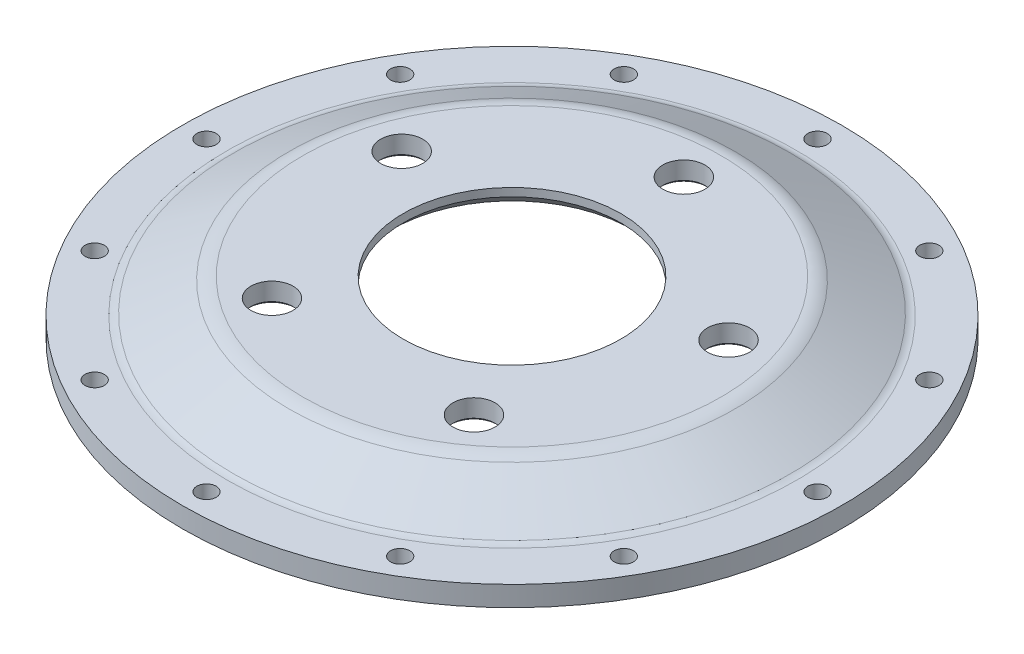
from build123d import *

# Parameters (mm, degrees)
SKETCH1_R           = 109.6
SKETCH1_R_2         = 3.2125
SKETCH1_R_3         = 93.6
BOSS_EXTRUDE1_DEPTH = 6.7
SKETCH2_R           = 72
SKETCH2_R_2         = 36.2
SKETCH2_R_3         = 7
BOSS_EXTRUDE3_DEPTH = 6.7
FILLET1_R           = 10
FILLET2_R           = 5
CHAMFER1_SIZE       = 4
CHAMFER2_SIZE       = 0.8
FILLET7_R           = 2.5
FILLET8_R           = 2.5


with BuildPart() as part:
    # Sketch1 → Boss-Extrude1 (new body)
    with BuildSketch(Plane(origin=(0, 0, 0), x_dir=(1, 0, 0), z_dir=(0, 1, 0))):
        with Locations(Location((0, 0, 0), (0, 0, 270))):
            Circle(SKETCH1_R)
        with Locations(Location((0, 101.6, 0), (0, 0, 270))):
            Circle(SKETCH1_R_2, mode=Mode.SUBTRACT)
        with Locations(Location((0, 0, 0), (0, 0, 270))):
            Circle(SKETCH1_R_3, mode=Mode.SUBTRACT)
        with Locations(Location((50.8, 87.988181025, 0), (0, 0, 270))):
            Circle(SKETCH1_R_2, mode=Mode.SUBTRACT)
        with Locations(Location((87.988181025, 50.8, 0), (0, 0, 270))):
            Circle(SKETCH1_R_2, mode=Mode.SUBTRACT)
        with Locations(Location((101.6, 0, 0), (0, 0, 270))):
            Circle(SKETCH1_R_2, mode=Mode.SUBTRACT)
        with Locations(Location((87.988181025, -50.8, 0), (0, 0, 270))):
            Circle(SKETCH1_R_2, mode=Mode.SUBTRACT)
        with Locations(Location((50.8, -87.988181024, 0), (0, 0, 270))):
            Circle(SKETCH1_R_2, mode=Mode.SUBTRACT)
        with Locations(Location((0, -101.6, 0), (0, 0, 270))):
            Circle(SKETCH1_R_2, mode=Mode.SUBTRACT)
        with Locations(Location((-50.8, -87.988181025, 0), (0, 0, 270))):
            Circle(SKETCH1_R_2, mode=Mode.SUBTRACT)
        with Locations(Location((-87.988181024, -50.8, 0), (0, 0, 270))):
            Circle(SKETCH1_R_2, mode=Mode.SUBTRACT)
        with Locations(Location((-101.6, 0, 0), (0, 0, 270))):
            Circle(SKETCH1_R_2, mode=Mode.SUBTRACT)
        with Locations(Location((-87.988181024, 50.8, 0), (0, 0, 270))):
            Circle(SKETCH1_R_2, mode=Mode.SUBTRACT)
        with Locations(Location((-50.8, 87.988181024, 0), (0, 0, 270))):
            Circle(SKETCH1_R_2, mode=Mode.SUBTRACT)
    extrude(amount=BOSS_EXTRUDE1_DEPTH)



with BuildPart() as body_2:
    # Sketch2 → Boss-Extrude3 (new body)
    with BuildSketch(Plane(origin=(0, 17.95, 0), x_dir=(1, 0, 0), z_dir=(0, 1, 0))):
        with Locations(Location((0, 0, 0), (0, 0, 270))):
            Circle(SKETCH2_R)
        with Locations(Location((0, 0, 0), (0, 0, 270))):
            Circle(SKETCH2_R_2, mode=Mode.SUBTRACT)
        with Locations(Location((0, 57.15, 0), (0, 0, 270))):
            Circle(SKETCH2_R_3, mode=Mode.SUBTRACT)
        with Locations(Location((54.352879906, 17.660321229, 0), (0, 0, 270))):
            Circle(SKETCH2_R_3, mode=Mode.SUBTRACT)
        with Locations(Location((33.591927169, -46.235321229, 0), (0, 0, 270))):
            Circle(SKETCH2_R_3, mode=Mode.SUBTRACT)
        with Locations(Location((-33.591927169, -46.235321229, 0), (0, 0, 270))):
            Circle(SKETCH2_R_3, mode=Mode.SUBTRACT)
        with Locations(Location((-54.352879906, 17.660321229, 0), (0, 0, 270))):
            Circle(SKETCH2_R_3, mode=Mode.SUBTRACT)
    extrude(amount=-BOSS_EXTRUDE3_DEPTH)


with BuildPart() as part_1:
    add(part.part)

    add(body_2.part)  # Sweep3 merges body 2
    # Sweep3: sweep along a curve in space
    with BuildLine() as sweep3_path:
        ThreePointArc((0, 11.25, 72), (50.911688245, 11.25, 50.911688245), (72, 11.25, 0))
        ThreePointArc((72, 11.25, 0), (50.911688245, 11.25, -50.911688245), (0, 11.25, -72))
        ThreePointArc((0, 11.25, -72), (-50.911688245, 11.25, -50.911688245), (-72, 11.25, 0))
        ThreePointArc((-72, 11.25, 0), (-50.911688245, 11.25, 50.911688245), (0, 11.25, 72))
    # Sketch4 → Sweep3 (sweep)
    with BuildSketch(Plane.XY):
        Polygon((72, 17.95), (93.6, 6.7), (93.6, 0), (72, 11.25), align=None)
    sweep(path=sweep3_path.line)

    # Fillet1
    fillet1_edges = [part_1.edges().sort_by_distance(p)[0] for p in [
        (50.911688245, 17.95, 50.911688245),
    ]]
    fillet(fillet1_edges, radius=FILLET1_R)

    # Fillet2
    fillet2_edges = [part_1.edges().sort_by_distance(p)[0] for p in [
        (66.185194719, 6.7, 66.185194719),
    ]]
    fillet(fillet2_edges, radius=FILLET2_R)

    # Chamfer1
    chamfer1_edges = [part_1.edges().sort_by_distance(p)[0] for p in [
        (0, 11.25, -36.2),
    ]]
    chamfer(chamfer1_edges, length=CHAMFER1_SIZE)

    # Chamfer2
    chamfer2_edges = [part_1.edges().sort_by_distance(p)[0] for p in [
        (-54.352879906, 11.25, -24.660321229),
        (-33.591927169, 11.25, 39.235321229),
        (33.591927169, 11.25, 39.235321229),
        (54.352879906, 11.25, -24.660321229),
        (0, 11.25, -64.15),
    ]]
    chamfer(chamfer2_edges, length=CHAMFER2_SIZE)

    # Fillet7
    fillet7_edges = [part_1.edges().sort_by_distance(p)[0] for p in [
        (50.911688245, 11.25, -50.911688245),
    ]]
    fillet(fillet7_edges, radius=FILLET7_R)

    # Fillet8
    fillet8_edges = [part_1.edges().sort_by_distance(p)[0] for p in [
        (66.185194719, 0, -66.185194719),
    ]]
    fillet(fillet8_edges, radius=FILLET8_R)


solid = part_1.part
